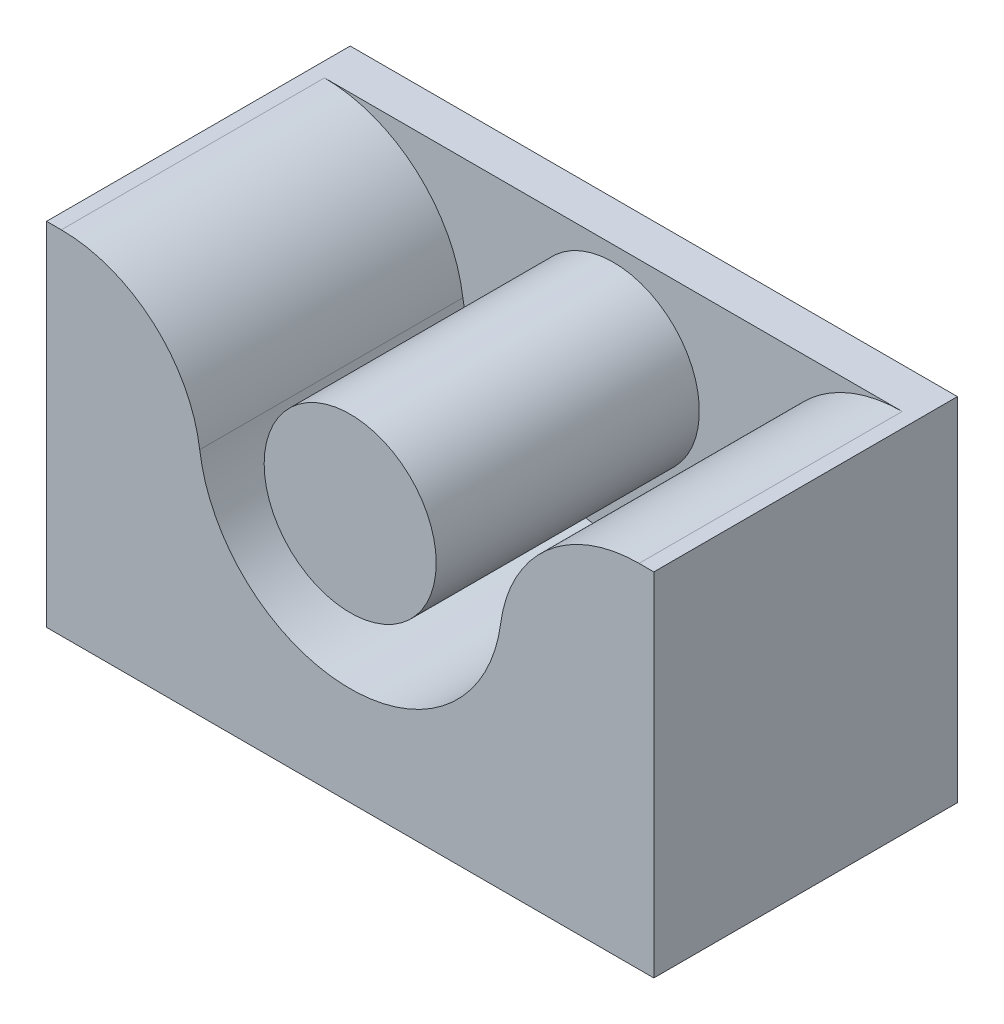
from build123d import *

# Parameters (mm, degrees)
CROQUIS2_W              = 30
CROQUIS2_H              = 17.375045376
SALIENTE_EXTRUIR1_DEPTH = 2
CROQUIS3_R              = 4.25
SALIENTE_EXTRUIR2_DEPTH = 13
CROQUIS4_R              = 5
CORTAR_EXTRUIR1_DEPTH   = 4.6


with BuildPart() as part:
    # Croquis2 → Saliente-Extruir1 (new body)
    with BuildSketch(Plane.XY):
        with Locations((0, -3.687522688)):
            Rectangle(CROQUIS2_W, CROQUIS2_H)
    extrude(amount=SALIENTE_EXTRUIR1_DEPTH)

    # Croquis3 → Saliente-Extruir2 (add)
    with BuildSketch(Plane.XY.offset(2)):
        Circle(CROQUIS3_R)
        with BuildLine():
            Line((-15, 5), (-14.271293534, 5))
            ThreePointArc((-14.271293534, 5), (-9.727126272, 3.291298824), (-7.434621256, -0.98813298))
            ThreePointArc((-7.434621256, -0.98813298), (0, -7.5), (7.434621256, -0.98813298))
            ThreePointArc((7.434621256, -0.98813298), (9.727126272, 3.291298824), (14.271293534, 5))
            Line((14.271293534, 5), (15, 5))
            Line((15, 5), (15, -12.375045376))
            Line((15, -12.375045376), (-15, -12.375045376))
            Line((-15, -12.375045376), (-15, 5))
        make_face()
    extrude(amount=SALIENTE_EXTRUIR2_DEPTH)

    # Croquis4 → Cortar-Extruir1 (cut)
    with BuildSketch(Plane.XZ.offset(12.375045376)):
        with Locations((-7, 7.5)):
            Circle(CROQUIS4_R)
        with Locations((7, 7.5)):
            Circle(CROQUIS4_R)
    extrude(amount=-CORTAR_EXTRUIR1_DEPTH, mode=Mode.SUBTRACT)


solid = part.part
